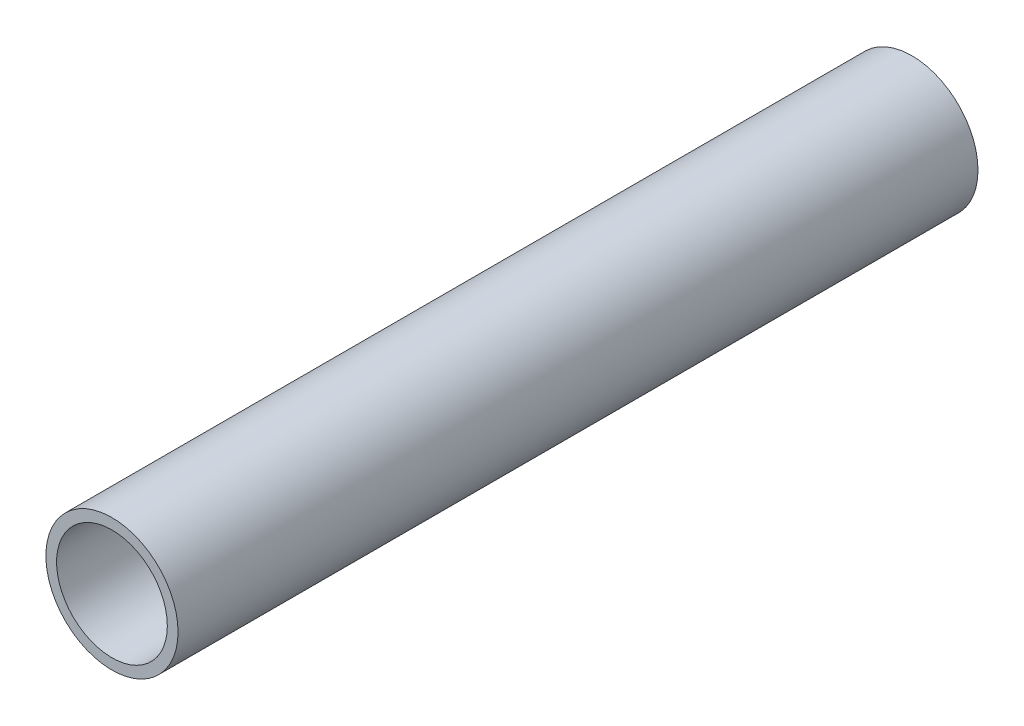
from build123d import *

# Parameters (mm, degrees)
SKETCH1_R                        = 24.13
SKETCH1_R_2                      = 20.2184
BOSS_EXTRUDE1_DEPTH              = 292.1
F_1_4_0_25_DIAMETER_HOLE1_REACH  = 460.245
F_1_4_0_25_DIAMETER_HOLE1_BORE_R = 3.175


with BuildPart() as part:
    # Sketch1 → Boss-Extrude1 (new body)
    with BuildSketch(Plane.XY):
        with Locations((-325.637336552, 52.475)):
            Circle(SKETCH1_R)
        with Locations((-325.637336552, 52.475)):
            Circle(SKETCH1_R_2, mode=Mode.SUBTRACT)
    extrude(amount=-BOSS_EXTRUDE1_DEPTH)

    # 1/4 (0.25) Diameter Hole1 bore → 1/4 (0.25) Diameter Hole1 (cut, up to next)
    with BuildSketch(Plane(origin=(0, 28.345, 0), x_dir=(-1, 0, 0), z_dir=(0, -1, 0)), mode=Mode.PRIVATE) as f_1_4_0_25_diameter_hole1_sk1:
        with Locations((325.637336552, 50.8)):
            Circle(F_1_4_0_25_DIAMETER_HOLE1_BORE_R)
    f_1_4_0_25_diameter_hole1_tool1 = extrude(f_1_4_0_25_diameter_hole1_sk1.sketch, amount=-F_1_4_0_25_DIAMETER_HOLE1_REACH, mode=Mode.PRIVATE) & part.part
    # 1/4 (0.25) Diameter Hole1 bore → 1/4 (0.25) Diameter Hole1 (cut, up to next)
    with BuildSketch(Plane(origin=(0, 28.345, 0), x_dir=(-1, 0, 0), z_dir=(0, -1, 0)), mode=Mode.PRIVATE) as f_1_4_0_25_diameter_hole1_sk2:
        with Locations((325.637336552, 241.3)):
            Circle(F_1_4_0_25_DIAMETER_HOLE1_BORE_R)
    f_1_4_0_25_diameter_hole1_tool2 = extrude(f_1_4_0_25_diameter_hole1_sk2.sketch, amount=-F_1_4_0_25_DIAMETER_HOLE1_REACH, mode=Mode.PRIVATE) & part.part
    add(f_1_4_0_25_diameter_hole1_tool1.solids().sort_by_distance((-325.637337, 28.345, -50.8))[0], mode=Mode.SUBTRACT)
    add(f_1_4_0_25_diameter_hole1_tool2.solids().sort_by_distance((-325.637337, 28.345, -241.3))[0], mode=Mode.SUBTRACT)


solid = part.part
